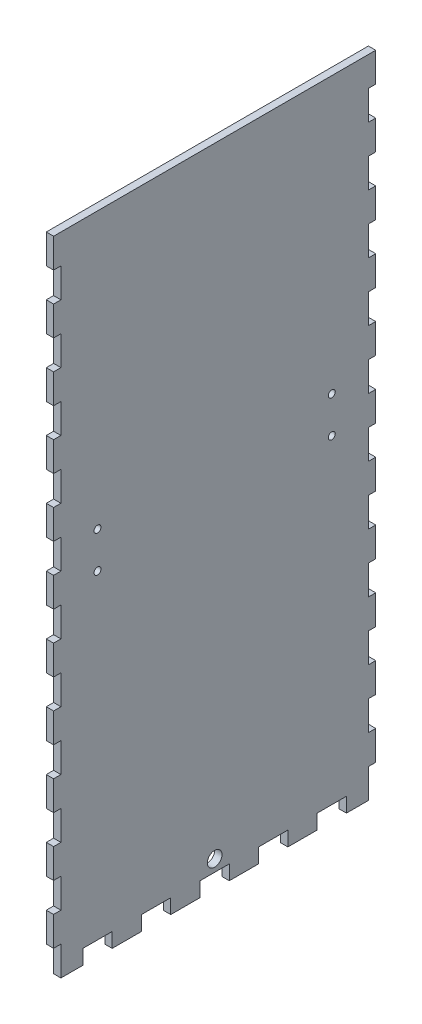
from build123d import *

# Parameters (mm, degrees)
SKETCH1_W                   = 483.489
SKETCH1_H                   = 139.7
BOSS_EXTRUDE1_DEPTH         = 6.35
SKETCH2_W                   = 483.489
SKETCH2_H                   = 139.7
SKETCH2_W_2                 = 477.139
SKETCH2_H_2                 = 133.35
BOSS_EXTRUDE2_DEPTH         = 299.212
SKETCH3_W                   = 5.588
SKETCH3_H                   = 16.933333333
SKETCH3_H_2                 = 16.933333334
DOOR_SLOT_DEPTH             = 12.7
SKETCH4_W                   = 6.35
SKETCH4_H                   = 15.9512
DOOR_GUIDE_HOLES_DEPTH      = 3.175
LEVERHOLE_CUT_REACH         = 141.7
LEVER_HOLES_R               = 1.5
LEVER_HOLES_W               = 25.4
LEVER_HOLES_H               = 7.62
LEVER_HOLES_W_2             = 4
LEVER_HOLES_H_2             = 6.35
LEVER_HOLES_2_R             = 1.5
LBRACKET_THRU_HOLES_DEPTH   = 140.7
SKETCH8_R                   = 3.175
TETHER_HOLE_DEPTH           = 484.489
DOOR_GUIDE_ROOF_SLOTS_REACH = 141.7
SKETCH16_W                  = 9.525
SKETCH16_H                  = 15.744198015
SKETCH16_W_2                = 483.489
SKETCH16_H_2                = 25.4
SKETCH17_W                  = 480.314
SKETCH17_H                  = 280.162
CUT_EXTRUDE1_DEPTH          = 140.7
LEFT_RIGHT_W                = 12.7
LEFT_RIGHT_H                = 6.35
LEFT_RIGHT_W_2              = 3.175
LEFT_RIGHT_H_2              = 12.734636364
LEFT_RIGHT_H_3              = 12.734636363
CUT_EXTRUDE2_DEPTH          = 4.175
SKETCH18_R                  = 1.499997
CUT_EXTRUDE3_DEPTH          = 4.175


with BuildPart() as part:
    # Sketch1 → Boss-Extrude1 (new body)
    with BuildSketch(Plane(origin=(0, 0, 0), x_dir=(1, 0, 0), z_dir=(0, 1, 0))):
        Rectangle(SKETCH1_W, SKETCH1_H)
    extrude(amount=BOSS_EXTRUDE1_DEPTH)

    # Sketch2 → Boss-Extrude2 (add)
    with BuildSketch(Plane(origin=(0, 6.35, 0), x_dir=(1, 0, 0), z_dir=(0, 1, 0))):
        Rectangle(SKETCH2_W, SKETCH2_H)
        Rectangle(SKETCH2_W_2, SKETCH2_H_2, mode=Mode.SUBTRACT)
    extrude(amount=BOSS_EXTRUDE2_DEPTH)

    # Sketch3 → Door Slot (cut)
    with BuildSketch(Plane.XY.offset(69.85)):
        with BuildLine():
            Line((76.5175, 292.354), (76.5175, 6.35))
            Line((76.5175, 6.35), (83.1215, 6.35))
            Line((83.1215, 6.35), (83.1215, 283.240675824))
            ThreePointArc((83.1215, 283.240675824), (83.865448776, 285.036727048), (85.6615, 285.780675824))
            Line((85.6615, 285.780675824), (96.0755, 285.780675824))
            Line((96.0755, 285.780675824), (96.0755, 292.354))
            Line((96.0755, 292.354), (76.5175, 292.354))
        make_face()
        with Locations((66.6115, 80.433333334)):
            Rectangle(SKETCH3_W, SKETCH3_H)
        with Locations((66.6115, 50.8)):
            Rectangle(SKETCH3_W, SKETCH3_H_2)
        with Locations((66.6115, 21.166666667)):
            Rectangle(SKETCH3_W, SKETCH3_H)
        with BuildLine():
            Line((-83.1215, 283.240675824), (-83.1215, 6.35))
            Line((-83.1215, 6.35), (-76.5175, 6.35))
            Line((-76.5175, 6.35), (-76.5175, 292.354))
            Line((-76.5175, 292.354), (-96.0755, 292.354))
            Line((-96.0755, 292.354), (-96.0755, 285.780675824))
            Line((-96.0755, 285.780675824), (-85.6615, 285.780675824))
            ThreePointArc((-85.6615, 285.780675824), (-83.865448776, 285.036727048), (-83.1215, 283.240675824))
        make_face()
        with Locations((-66.6115, 80.433333334)):
            Rectangle(SKETCH3_W, SKETCH3_H)
        with Locations((-66.6115, 50.8)):
            Rectangle(SKETCH3_W, SKETCH3_H_2)
        with Locations((-66.6115, 21.166666667)):
            Rectangle(SKETCH3_W, SKETCH3_H)
    extrude(amount=-DOOR_SLOT_DEPTH, mode=Mode.SUBTRACT)

    # Sketch4 → Door Guide Holes (cut)
    with BuildSketch(Plane.XY.offset(-66.675)):
        with Locations((73.3425, 256.2352)):
            Rectangle(SKETCH4_W, SKETCH4_H)
        with Locations((73.3425, 227.584)):
            Rectangle(SKETCH4_W, SKETCH4_H)
        with Locations((73.3425, 198.9328)):
            Rectangle(SKETCH4_W, SKETCH4_H)
        with Locations((73.3425, 170.2816)):
            Rectangle(SKETCH4_W, SKETCH4_H)
        with Locations((73.3425, 141.6304)):
            Rectangle(SKETCH4_W, SKETCH4_H)
        with Locations((73.3425, 112.9792)):
            Rectangle(SKETCH4_W, SKETCH4_H)
        with Locations((73.3425, 84.328)):
            Rectangle(SKETCH4_W, SKETCH4_H)
        with Locations((73.3425, 55.6768)):
            Rectangle(SKETCH4_W, SKETCH4_H)
        with Locations((73.3425, 27.0256)):
            Rectangle(SKETCH4_W, SKETCH4_H)
        with Locations((-99.2505, 284.8864)):
            Rectangle(SKETCH4_W, SKETCH4_H)
        with Locations((-99.2505, 256.2352)):
            Rectangle(SKETCH4_W, SKETCH4_H)
        with Locations((-99.2505, 227.584)):
            Rectangle(SKETCH4_W, SKETCH4_H)
        with Locations((-99.2505, 198.9328)):
            Rectangle(SKETCH4_W, SKETCH4_H)
        with Locations((-99.2505, 170.2816)):
            Rectangle(SKETCH4_W, SKETCH4_H)
        with Locations((-99.2505, 141.6304)):
            Rectangle(SKETCH4_W, SKETCH4_H)
        with Locations((-99.2505, 112.9792)):
            Rectangle(SKETCH4_W, SKETCH4_H)
        with Locations((-99.2505, 84.328)):
            Rectangle(SKETCH4_W, SKETCH4_H)
        with Locations((-99.2505, 55.6768)):
            Rectangle(SKETCH4_W, SKETCH4_H)
        with Locations((-99.2505, 27.0256)):
            Rectangle(SKETCH4_W, SKETCH4_H)
        with Locations((99.2505, 284.8864)):
            Rectangle(SKETCH4_W, SKETCH4_H)
        with Locations((99.2505, 256.2352)):
            Rectangle(SKETCH4_W, SKETCH4_H)
        with Locations((99.2505, 227.584)):
            Rectangle(SKETCH4_W, SKETCH4_H)
        with Locations((99.2505, 198.9328)):
            Rectangle(SKETCH4_W, SKETCH4_H)
        with Locations((99.2505, 170.2816)):
            Rectangle(SKETCH4_W, SKETCH4_H)
        with Locations((99.2505, 141.6304)):
            Rectangle(SKETCH4_W, SKETCH4_H)
        with Locations((99.2505, 112.9792)):
            Rectangle(SKETCH4_W, SKETCH4_H)
        with Locations((99.2505, 84.328)):
            Rectangle(SKETCH4_W, SKETCH4_H)
        with Locations((99.2505, 55.6768)):
            Rectangle(SKETCH4_W, SKETCH4_H)
        with Locations((99.2505, 27.0256)):
            Rectangle(SKETCH4_W, SKETCH4_H)
        with Locations((-73.3425, 284.8864)):
            Rectangle(SKETCH4_W, SKETCH4_H)
        with Locations((-73.3425, 256.2352)):
            Rectangle(SKETCH4_W, SKETCH4_H)
        with Locations((-73.3425, 227.584)):
            Rectangle(SKETCH4_W, SKETCH4_H)
        with Locations((-73.3425, 198.9328)):
            Rectangle(SKETCH4_W, SKETCH4_H)
        with Locations((-73.3425, 170.2816)):
            Rectangle(SKETCH4_W, SKETCH4_H)
        with Locations((-73.3425, 141.6304)):
            Rectangle(SKETCH4_W, SKETCH4_H)
        with Locations((-73.3425, 112.9792)):
            Rectangle(SKETCH4_W, SKETCH4_H)
        with Locations((-73.3425, 84.328)):
            Rectangle(SKETCH4_W, SKETCH4_H)
        with Locations((-73.3425, 55.6768)):
            Rectangle(SKETCH4_W, SKETCH4_H)
        with Locations((-73.3425, 27.0256)):
            Rectangle(SKETCH4_W, SKETCH4_H)
        with Locations((73.3425, 284.8864)):
            Rectangle(SKETCH4_W, SKETCH4_H)
    extrude(amount=-DOOR_GUIDE_HOLES_DEPTH, mode=Mode.SUBTRACT)

    # Lever Holes → LeverHole Cut (cut, up to next)
    with BuildSketch(Plane.XY.offset(-69.85), mode=Mode.PRIVATE) as leverhole_cut_sk1:
        with Locations((222.6945, 160.655)):
            Circle(LEVER_HOLES_R)
    leverhole_cut_tool1 = extrude(leverhole_cut_sk1.sketch, amount=LEVERHOLE_CUT_REACH, mode=Mode.PRIVATE) & part.part
    add(leverhole_cut_tool1.solids().sort_by_distance((222.6945, 160.655, -69.85))[0], mode=Mode.SUBTRACT)
    # Lever Holes → LeverHole Cut (cut, up to next)
    with BuildSketch(Plane.XY.offset(-69.85), mode=Mode.PRIVATE) as leverhole_cut_sk2:
        with Locations((222.6945, 144.907)):
            Circle(LEVER_HOLES_R)
    leverhole_cut_tool2 = extrude(leverhole_cut_sk2.sketch, amount=LEVERHOLE_CUT_REACH, mode=Mode.PRIVATE) & part.part
    add(leverhole_cut_tool2.solids().sort_by_distance((222.6945, 144.907, -69.85))[0], mode=Mode.SUBTRACT)
    # Lever Holes → LeverHole Cut (cut, up to next)
    with BuildSketch(Plane.XY.offset(-69.85), mode=Mode.PRIVATE) as leverhole_cut_sk3:
        with Locations((-222.6945, 160.655)):
            Circle(LEVER_HOLES_R)
    leverhole_cut_tool3 = extrude(leverhole_cut_sk3.sketch, amount=LEVERHOLE_CUT_REACH, mode=Mode.PRIVATE) & part.part
    add(leverhole_cut_tool3.solids().sort_by_distance((-222.6945, 160.655, -69.85))[0], mode=Mode.SUBTRACT)
    # Lever Holes → LeverHole Cut (cut, up to next)
    with BuildSketch(Plane.XY.offset(-69.85), mode=Mode.PRIVATE) as leverhole_cut_sk4:
        with Locations((-222.6945, 144.907)):
            Circle(LEVER_HOLES_R)
    leverhole_cut_tool4 = extrude(leverhole_cut_sk4.sketch, amount=LEVERHOLE_CUT_REACH, mode=Mode.PRIVATE) & part.part
    add(leverhole_cut_tool4.solids().sort_by_distance((-222.6945, 144.907, -69.85))[0], mode=Mode.SUBTRACT)
    # Lever Holes → LeverHole Cut (cut, up to next)
    with BuildSketch(Plane.XY.offset(-69.85), mode=Mode.PRIVATE) as leverhole_cut_sk5:
        with Locations((-46.9175, 33.8749894)):
            Rectangle(LEVER_HOLES_W, LEVER_HOLES_H)
    leverhole_cut_tool5 = extrude(leverhole_cut_sk5.sketch, amount=LEVERHOLE_CUT_REACH, mode=Mode.PRIVATE) & part.part
    add(leverhole_cut_tool5.solids().sort_by_distance((-46.9175, 33.874989, -69.85))[0], mode=Mode.SUBTRACT)
    # Lever Holes → LeverHole Cut (cut, up to next)
    with BuildSketch(Plane.XY.offset(-69.85), mode=Mode.PRIVATE) as leverhole_cut_sk6:
        with Locations((-58.1675, 13.175)):
            Rectangle(LEVER_HOLES_W_2, LEVER_HOLES_H_2)
    leverhole_cut_tool6 = extrude(leverhole_cut_sk6.sketch, amount=LEVERHOLE_CUT_REACH, mode=Mode.PRIVATE) & part.part
    add(leverhole_cut_tool6.solids().sort_by_distance((-58.1675, 13.175, -69.85))[0], mode=Mode.SUBTRACT)
    # Lever Holes → LeverHole Cut (cut, up to next)
    with BuildSketch(Plane.XY.offset(-69.85), mode=Mode.PRIVATE) as leverhole_cut_sk7:
        with Locations((-12.1675068, 13.175)):
            Rectangle(LEVER_HOLES_W_2, LEVER_HOLES_H_2)
    leverhole_cut_tool7 = extrude(leverhole_cut_sk7.sketch, amount=LEVERHOLE_CUT_REACH, mode=Mode.PRIVATE) & part.part
    add(leverhole_cut_tool7.solids().sort_by_distance((-12.167507, 13.175, -69.85))[0], mode=Mode.SUBTRACT)
    # Lever Holes → LeverHole Cut (cut, up to next)
    with BuildSketch(Plane.XY.offset(-69.85), mode=Mode.PRIVATE) as leverhole_cut_sk8:
        with Locations((12.1675068, 13.175)):
            Rectangle(LEVER_HOLES_W_2, LEVER_HOLES_H_2)
    leverhole_cut_tool8 = extrude(leverhole_cut_sk8.sketch, amount=LEVERHOLE_CUT_REACH, mode=Mode.PRIVATE) & part.part
    add(leverhole_cut_tool8.solids().sort_by_distance((12.167507, 13.175, -69.85))[0], mode=Mode.SUBTRACT)
    # Lever Holes → LeverHole Cut (cut, up to next)
    with BuildSketch(Plane.XY.offset(-69.85), mode=Mode.PRIVATE) as leverhole_cut_sk9:
        with Locations((46.9175, 33.8749894)):
            Rectangle(LEVER_HOLES_W, LEVER_HOLES_H)
    leverhole_cut_tool9 = extrude(leverhole_cut_sk9.sketch, amount=LEVERHOLE_CUT_REACH, mode=Mode.PRIVATE) & part.part
    add(leverhole_cut_tool9.solids().sort_by_distance((46.9175, 33.874989, -69.85))[0], mode=Mode.SUBTRACT)
    # Lever Holes → LeverHole Cut (cut, up to next)
    with BuildSketch(Plane.XY.offset(-69.85), mode=Mode.PRIVATE) as leverhole_cut_sk10:
        with Locations((58.1675, 13.175)):
            Rectangle(LEVER_HOLES_W_2, LEVER_HOLES_H_2)
    leverhole_cut_tool10 = extrude(leverhole_cut_sk10.sketch, amount=LEVERHOLE_CUT_REACH, mode=Mode.PRIVATE) & part.part
    add(leverhole_cut_tool10.solids().sort_by_distance((58.1675, 13.175, -69.85))[0], mode=Mode.SUBTRACT)

    # Lever Holes_2 → Lbracket Thru Holes (cut, through all)
    with BuildSketch(Plane.XY.offset(-69.85)):
        with Locations((-222.6945, 160.655)):
            Circle(LEVER_HOLES_2_R)
        with Locations((-222.6945, 144.907)):
            Circle(LEVER_HOLES_2_R)
        with Locations((222.6945, 160.655)):
            Circle(LEVER_HOLES_2_R)
        with Locations((222.6945, 144.907)):
            Circle(LEVER_HOLES_2_R)
    extrude(amount=LBRACKET_THRU_HOLES_DEPTH, mode=Mode.SUBTRACT)

    # Sketch8 → Tether Hole (cut, through all)
    with BuildSketch(Plane.ZY.offset(241.7445)):
        with Locations((0, 11.43)):
            Circle(SKETCH8_R)
    extrude(amount=-TETHER_HOLE_DEPTH, mode=Mode.SUBTRACT)

    # Sketch16 → Door Guide Roof Slots (cut, up to next)
    with BuildSketch(Plane.XY.offset(69.85), mode=Mode.PRIVATE) as door_guide_roof_slots_sk1:
        with Locations((54.102, 267.525769227)):
            Rectangle(SKETCH16_W, SKETCH16_H)
    door_guide_roof_slots_tool1 = extrude(door_guide_roof_slots_sk1.sketch, amount=-DOOR_GUIDE_ROOF_SLOTS_REACH, mode=Mode.PRIVATE) & part.part
    add(door_guide_roof_slots_tool1.solids().sort_by_distance((54.102, 267.525769, 69.85))[0], mode=Mode.SUBTRACT)
    # Sketch16 → Door Guide Roof Slots (cut, up to next)
    with BuildSketch(Plane.XY.offset(69.85), mode=Mode.PRIVATE) as door_guide_roof_slots_sk2:
        with Locations((118.491, 267.525769227)):
            Rectangle(SKETCH16_W, SKETCH16_H)
    door_guide_roof_slots_tool2 = extrude(door_guide_roof_slots_sk2.sketch, amount=-DOOR_GUIDE_ROOF_SLOTS_REACH, mode=Mode.PRIVATE) & part.part
    add(door_guide_roof_slots_tool2.solids().sort_by_distance((118.491, 267.525769, 69.85))[0], mode=Mode.SUBTRACT)
    # Sketch16 → Door Guide Roof Slots (cut, up to next)
    with BuildSketch(Plane.XY.offset(69.85), mode=Mode.PRIVATE) as door_guide_roof_slots_sk3:
        with Locations((-118.491, 267.525769227)):
            Rectangle(SKETCH16_W, SKETCH16_H)
    door_guide_roof_slots_tool3 = extrude(door_guide_roof_slots_sk3.sketch, amount=-DOOR_GUIDE_ROOF_SLOTS_REACH, mode=Mode.PRIVATE) & part.part
    add(door_guide_roof_slots_tool3.solids().sort_by_distance((-118.491, 267.525769, 69.85))[0], mode=Mode.SUBTRACT)
    # Sketch16 → Door Guide Roof Slots (cut, up to next)
    with BuildSketch(Plane.XY.offset(69.85), mode=Mode.PRIVATE) as door_guide_roof_slots_sk4:
        with Locations((-54.102, 267.525769227)):
            Rectangle(SKETCH16_W, SKETCH16_H)
    door_guide_roof_slots_tool4 = extrude(door_guide_roof_slots_sk4.sketch, amount=-DOOR_GUIDE_ROOF_SLOTS_REACH, mode=Mode.PRIVATE) & part.part
    add(door_guide_roof_slots_tool4.solids().sort_by_distance((-54.102, 267.525769, 69.85))[0], mode=Mode.SUBTRACT)
    # Sketch16 → Door Guide Roof Slots (cut, up to next)
    with BuildSketch(Plane.XY.offset(69.85), mode=Mode.PRIVATE) as door_guide_roof_slots_sk5:
        with Locations((0, 292.862)):
            Rectangle(SKETCH16_W_2, SKETCH16_H_2)
    door_guide_roof_slots_tool5 = extrude(door_guide_roof_slots_sk5.sketch, amount=-DOOR_GUIDE_ROOF_SLOTS_REACH, mode=Mode.PRIVATE) & part.part
    add(door_guide_roof_slots_tool5.solids().sort_by_distance((0, 292.862, 69.85))[0], mode=Mode.SUBTRACT)

    # Sketch17 → Cut-Extrude1 (cut, through all)
    with BuildSketch(Plane.XY.offset(69.85)):
        with Locations((1.5875, 140.081)):
            Rectangle(SKETCH17_W, SKETCH17_H)
    extrude(amount=-CUT_EXTRUDE1_DEPTH, mode=Mode.SUBTRACT)

    # Left_Right → Cut-Extrude2 (cut, through all)
    with BuildSketch(Plane.ZY.offset(241.7445)):
        with Locations((50.8, 3.175)):
            Rectangle(LEFT_RIGHT_W, LEFT_RIGHT_H)
        with Locations((68.2625, 6.367318182)):
            Rectangle(LEFT_RIGHT_W_2, LEFT_RIGHT_H_2)
        with Locations((25.4, 3.175)):
            Rectangle(LEFT_RIGHT_W, LEFT_RIGHT_H)
        with Locations((68.2625, 31.836590909)):
            Rectangle(LEFT_RIGHT_W_2, LEFT_RIGHT_H_2)
        with Locations((0, 3.175)):
            Rectangle(LEFT_RIGHT_W, LEFT_RIGHT_H)
        with Locations((68.2625, 57.305863637)):
            Rectangle(LEFT_RIGHT_W_2, LEFT_RIGHT_H_3)
        with Locations((-25.4, 3.175)):
            Rectangle(LEFT_RIGHT_W, LEFT_RIGHT_H)
        with Locations((68.2625, 82.775136363)):
            Rectangle(LEFT_RIGHT_W_2, LEFT_RIGHT_H_3)
        with Locations((-50.8, 3.175)):
            Rectangle(LEFT_RIGHT_W, LEFT_RIGHT_H)
        with Locations((68.2625, 108.244409091)):
            Rectangle(LEFT_RIGHT_W_2, LEFT_RIGHT_H_2)
        with Locations((-68.2625, 6.367318182)):
            Rectangle(LEFT_RIGHT_W_2, LEFT_RIGHT_H_2)
        with Locations((68.2625, 133.713681818)):
            Rectangle(LEFT_RIGHT_W_2, LEFT_RIGHT_H_2)
        with Locations((-68.2625, 31.836590909)):
            Rectangle(LEFT_RIGHT_W_2, LEFT_RIGHT_H_2)
        with Locations((68.2625, 159.182954546)):
            Rectangle(LEFT_RIGHT_W_2, LEFT_RIGHT_H_3)
        with Locations((-68.2625, 57.305863637)):
            Rectangle(LEFT_RIGHT_W_2, LEFT_RIGHT_H_3)
        with Locations((68.2625, 184.652227273)):
            Rectangle(LEFT_RIGHT_W_2, LEFT_RIGHT_H_2)
        with Locations((-68.2625, 82.775136363)):
            Rectangle(LEFT_RIGHT_W_2, LEFT_RIGHT_H_3)
        with Locations((68.2625, 210.1215)):
            Rectangle(LEFT_RIGHT_W_2, LEFT_RIGHT_H_2)
        with Locations((-68.2625, 108.244409091)):
            Rectangle(LEFT_RIGHT_W_2, LEFT_RIGHT_H_2)
        with Locations((68.2625, 235.590772727)):
            Rectangle(LEFT_RIGHT_W_2, LEFT_RIGHT_H_2)
        with Locations((-68.2625, 133.713681818)):
            Rectangle(LEFT_RIGHT_W_2, LEFT_RIGHT_H_2)
        with Locations((68.2625, 261.060045455)):
            Rectangle(LEFT_RIGHT_W_2, LEFT_RIGHT_H_3)
        with Locations((-68.2625, 159.182954546)):
            Rectangle(LEFT_RIGHT_W_2, LEFT_RIGHT_H_3)
        with Locations((-68.2625, 184.652227273)):
            Rectangle(LEFT_RIGHT_W_2, LEFT_RIGHT_H_2)
        with Locations((-68.2625, 210.1215)):
            Rectangle(LEFT_RIGHT_W_2, LEFT_RIGHT_H_2)
        with Locations((-68.2625, 235.590772727)):
            Rectangle(LEFT_RIGHT_W_2, LEFT_RIGHT_H_2)
        with Locations((-68.2625, 261.060045455)):
            Rectangle(LEFT_RIGHT_W_2, LEFT_RIGHT_H_3)
    extrude(amount=-CUT_EXTRUDE2_DEPTH, mode=Mode.SUBTRACT)

    # Sketch18 → Cut-Extrude3 (cut, through all)
    with BuildSketch(Plane.ZY.offset(241.7445)):
        with Locations((-50.8, 160.655)):
            Circle(SKETCH18_R)
        with Locations((-50.8, 144.907)):
            Circle(SKETCH18_R)
        with Locations((50.8, 144.907)):
            Circle(SKETCH18_R)
        with Locations((50.8, 160.655)):
            Circle(SKETCH18_R)
    extrude(amount=-CUT_EXTRUDE3_DEPTH, mode=Mode.SUBTRACT)


solid = part.part
